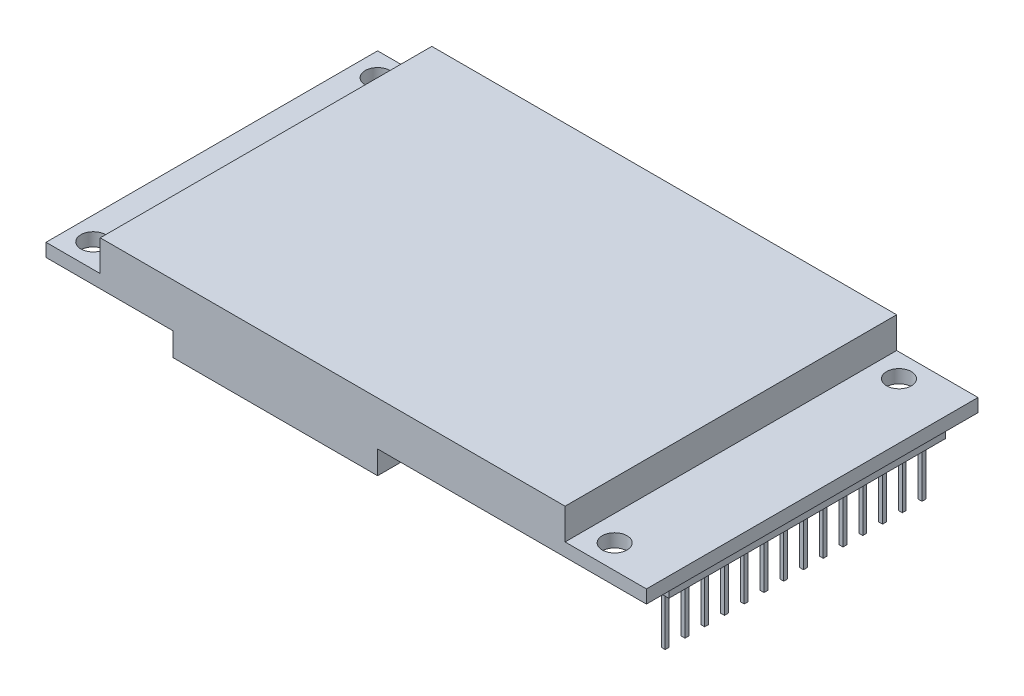
from build123d import *

# Parameters (mm, degrees)
SZKIC1_W                    = 77.5
SZKIC1_H                    = 42.8
SZKIC1_R                    = 1.6
DODANIE_WYCI_GNI_CIE1_DEPTH = 1.7
SZKIC2_W                    = 60
SZKIC2_H                    = 42.8
DODANIE_WYCI_GNI_CIE2_DEPTH = 4
DODANIE_WYCI_GNI_CIE3_DEPTH = 3
SZKIC4_W                    = 3.5
SZKIC4_H                    = 35.7
DODANIE_WYCI_GNI_CIE4_DEPTH = 8.5
SZKIC5_W                    = 20.589223083
SZKIC5_H                    = 59.264583933
SZKIC5_W_2                  = 0.5
SZKIC5_H_2                  = 0.5
WYTNIJ_WYCI_GNI_CIE1_DEPTH  = 7


with BuildPart() as part:
    # Szkic1 → Dodanie-wyciągnięcie1 (new body)
    with BuildSketch(Plane(origin=(0, 0, 0), x_dir=(1, 0, 0), z_dir=(0, 1, 0))):
        Rectangle(SZKIC1_W, SZKIC1_H)
        with Locations((-35.75, 18.4)):
            Circle(SZKIC1_R, mode=Mode.SUBTRACT)
        with Locations((31.55, 18.4)):
            Circle(SZKIC1_R, mode=Mode.SUBTRACT)
        with Locations((31.55, -18.3)):
            Circle(SZKIC1_R, mode=Mode.SUBTRACT)
        with Locations((-35.75, -18.3)):
            Circle(SZKIC1_R, mode=Mode.SUBTRACT)
    extrude(amount=DODANIE_WYCI_GNI_CIE1_DEPTH)

    # Szkic2 → Dodanie-wyciągnięcie2 (add)
    with BuildSketch(Plane(origin=(0, 1.7, 0), x_dir=(1, 0, 0), z_dir=(0, 1, 0))):
        with Locations((-1.75, 0)):
            Rectangle(SZKIC2_W, SZKIC2_H)
    extrude(amount=DODANIE_WYCI_GNI_CIE2_DEPTH)

    # Szkic3 → Dodanie-wyciągnięcie3 (add)
    with BuildSketch(Plane.XZ):
        Polygon((4.05, 21.4), (4.05, 4.5), (-20.45, 4.5), (-20.45, 9.5), (-22.35, 12.4), (-22.35, 21.4), align=None)
    extrude(amount=DODANIE_WYCI_GNI_CIE3_DEPTH)

    # Szkic4 → Dodanie-wyciągnięcie4 (add)
    with BuildSketch(Plane.XZ):
        with Locations((36.3, -0.05)):
            Rectangle(SZKIC4_W, SZKIC4_H)
    extrude(amount=DODANIE_WYCI_GNI_CIE4_DEPTH)

    # Szkic5 → Wytnij-wyciągnięcie1 (cut)
    with BuildSketch(Plane.XZ.offset(8.5)):
        with Locations((39.347598483, -1.41955971)):
            Rectangle(SZKIC5_W, SZKIC5_H)
        with Locations((36.3, 16.525)):
            Rectangle(SZKIC5_W_2, SZKIC5_H_2, mode=Mode.SUBTRACT)
        with Locations((36.3, 13.975)):
            Rectangle(SZKIC5_W_2, SZKIC5_H_2, mode=Mode.SUBTRACT)
        with Locations((36.3, 11.425)):
            Rectangle(SZKIC5_W_2, SZKIC5_H_2, mode=Mode.SUBTRACT)
        with Locations((36.3, 8.875)):
            Rectangle(SZKIC5_W_2, SZKIC5_H_2, mode=Mode.SUBTRACT)
        with Locations((36.3, 6.325)):
            Rectangle(SZKIC5_W_2, SZKIC5_H_2, mode=Mode.SUBTRACT)
        with Locations((36.3, 3.775)):
            Rectangle(SZKIC5_W_2, SZKIC5_H_2, mode=Mode.SUBTRACT)
        with Locations((36.3, 1.225)):
            Rectangle(SZKIC5_W_2, SZKIC5_H_2, mode=Mode.SUBTRACT)
        with Locations((36.3, -1.325)):
            Rectangle(SZKIC5_W_2, SZKIC5_H_2, mode=Mode.SUBTRACT)
        with Locations((36.3, -3.875)):
            Rectangle(SZKIC5_W_2, SZKIC5_H_2, mode=Mode.SUBTRACT)
        with Locations((36.3, -6.425)):
            Rectangle(SZKIC5_W_2, SZKIC5_H_2, mode=Mode.SUBTRACT)
        with Locations((36.3, -8.975)):
            Rectangle(SZKIC5_W_2, SZKIC5_H_2, mode=Mode.SUBTRACT)
        with Locations((36.3, -11.525)):
            Rectangle(SZKIC5_W_2, SZKIC5_H_2, mode=Mode.SUBTRACT)
        with Locations((36.3, -14.075)):
            Rectangle(SZKIC5_W_2, SZKIC5_H_2, mode=Mode.SUBTRACT)
        with Locations((36.3, -16.625)):
            Rectangle(SZKIC5_W_2, SZKIC5_H_2, mode=Mode.SUBTRACT)
    extrude(amount=-WYTNIJ_WYCI_GNI_CIE1_DEPTH, mode=Mode.SUBTRACT)


solid = part.part
